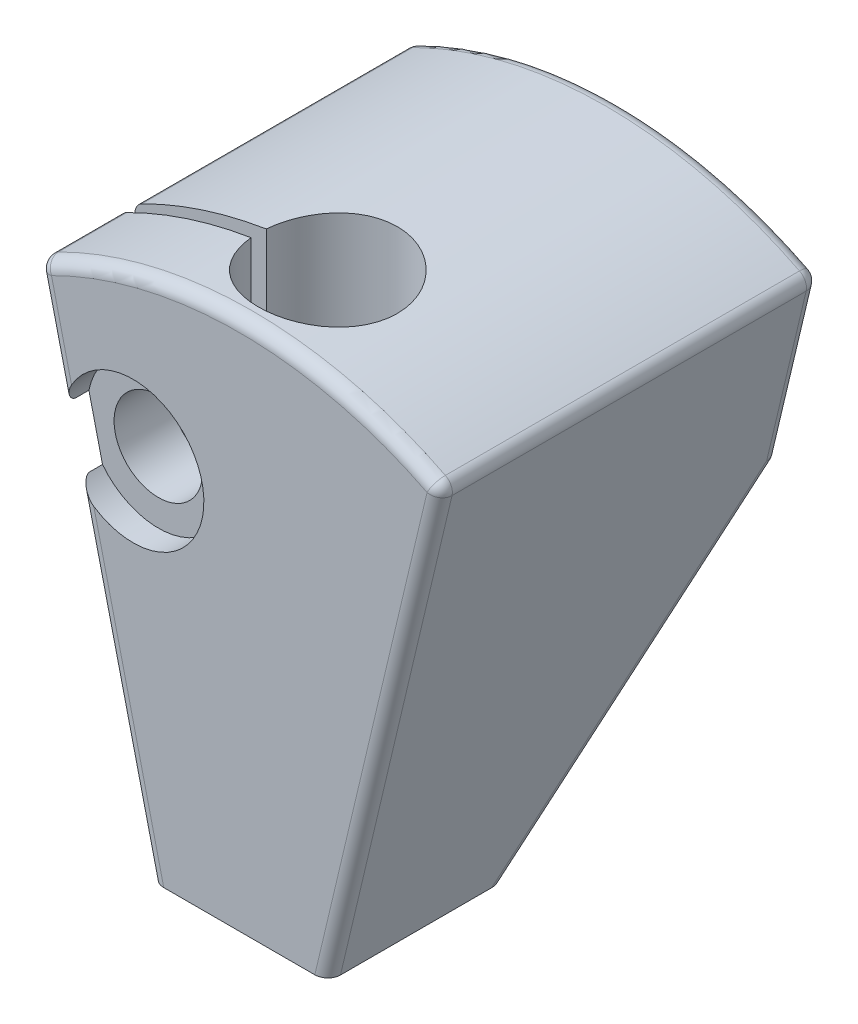
from build123d import *

# Parameters (mm, degrees)
EXTRUSION1_DEPTH             = 8
ESQUISSE2_OUTSIDE_W          = 24.072
ESQUISSE2_OUTSIDE_H          = 29.072
ENL_V_MAT_EXTRU_1_DEPTH      = 4.5
ENL_V_MAT_EXTRU_1_DEPTH_BACK = 12.5
CONG_1_R                     = 0.5
ESQUISSE3_R                  = 2.75
ENL_V_MAT_EXTRU_3_DEPTH      = 22
ESQUISSE4_W                  = 7.923568605
ESQUISSE4_H                  = 0.6
ENL_V_MAT_EXTRU_4_DEPTH      = 22.0000001
ESQUISSE5_R                  = 1.25
ENL_V_MAT_EXTRU_5_DEPTH      = 14
ENL_V_MAT_EXTRU_7_REACH      = 17
ESQUISSE7_R                  = 1.75
ESQUISSE6_R                  = 2.8
ENL_V_MAT_EXTRU_6_DEPTH      = 1


with BuildPart() as part:
    # Esquisse1 → Extrusion1 (new body, symmetric)
    with BuildSketch(Plane(origin=(0, 0, 0), x_dir=(0, 0, -1), z_dir=(1, 0, 0))):
        Polygon((3.5, 0), (-3.5, 0), (-3.5, 21), (11.5, 21), (11.5, 12), align=None)
    extrude(amount=EXTRUSION1_DEPTH, both=True)

    # Esquisse2 outside → Enlèv. mat.-Extru.1 (cut, two sides)
    with BuildSketch(Plane.XY) as enl_v_mat_extru_1_sk:
        with Locations((0, 10.5)):
            Rectangle(ESQUISSE2_OUTSIDE_W, ESQUISSE2_OUTSIDE_H)
        with BuildLine():
            Line((-3.5, 0), (-8, 19))
            ThreePointArc((-8, 19), (0, 21), (8, 19))
            Line((8, 19), (3.5, 0))
            Line((3.5, 0), (-3.5, 0))
        make_face(mode=Mode.SUBTRACT)
    extrude(amount=ENL_V_MAT_EXTRU_1_DEPTH, mode=Mode.SUBTRACT)
    extrude(enl_v_mat_extru_1_sk.sketch, amount=-ENL_V_MAT_EXTRU_1_DEPTH_BACK, mode=Mode.SUBTRACT)

    # Congé1
    cong_1_edges = [part.edges().sort_by_distance(p)[0] for p in [
        (0, 12, -11.5),
        (5.75, 9.5, 3.5),
        (7.171052632, 15.5, -11.5),
        (-7.171052632, 15.5, -11.5),
        (0, 21, -11.5),
        (-8, 19, -4),
        (-5.75, 9.5, 3.5),
        (8, 19, -4),
        (0, 21, 3.5),
        (-4.921052632, 6, -7.5),
        (4.921052632, 6, -7.5),
    ]]
    fillet(cong_1_edges, radius=CONG_1_R)

    # Esquisse3 → Enlèv. mat.-Extru.3 (cut, through all)
    with BuildSketch(Plane(origin=(0, 0, 0), x_dir=(1, 0, 0), z_dir=(0, 1, 0))):
        with Locations(Location((0, 0, 0), (0, 0, 90))):  # turned: the seam where the file's is
            Circle(ESQUISSE3_R)
    extrude(amount=ENL_V_MAT_EXTRU_3_DEPTH, mode=Mode.SUBTRACT)

    # Esquisse4 → Enlèv. mat.-Extru.4 (cut, through all)
    with BuildSketch(Plane(origin=(0, 0, 0), x_dir=(1, 0, 0), z_dir=(0, 1, 0))):
        with Locations((-3.961784303, 0)):
            Rectangle(ESQUISSE4_W, ESQUISSE4_H)
    extrude(amount=ENL_V_MAT_EXTRU_4_DEPTH, mode=Mode.SUBTRACT)

    # Esquisse5 → Enlèv. mat.-Extru.5 (cut)
    with BuildSketch(Plane.XY.offset(3.5)):
        with Locations((-4.2, 14)):
            Circle(ESQUISSE5_R)
    extrude(amount=-ENL_V_MAT_EXTRU_5_DEPTH, mode=Mode.SUBTRACT)

    # Esquisse7 → Enlèv. mat.-Extru.7 (cut, up to next)
    with BuildSketch(Plane.XY.offset(3.5), mode=Mode.PRIVATE) as enl_v_mat_extru_7_sk1:
        with Locations((-4.2, 14)):
            Circle(ESQUISSE7_R)
    enl_v_mat_extru_7_tool1 = extrude(enl_v_mat_extru_7_sk1.sketch, amount=-ENL_V_MAT_EXTRU_7_REACH, mode=Mode.PRIVATE) & part.part
    add(enl_v_mat_extru_7_tool1.solids().sort_by_distance((-4.2, 14, 3.5))[0], mode=Mode.SUBTRACT)

    # Esquisse6 → Enlèv. mat.-Extru.6 (cut)
    with BuildSketch(Plane.XY.offset(3.5)):
        with Locations((-4.2, 14)):
            Circle(ESQUISSE6_R)
    extrude(amount=-ENL_V_MAT_EXTRU_6_DEPTH, mode=Mode.SUBTRACT)


solid = part.part
